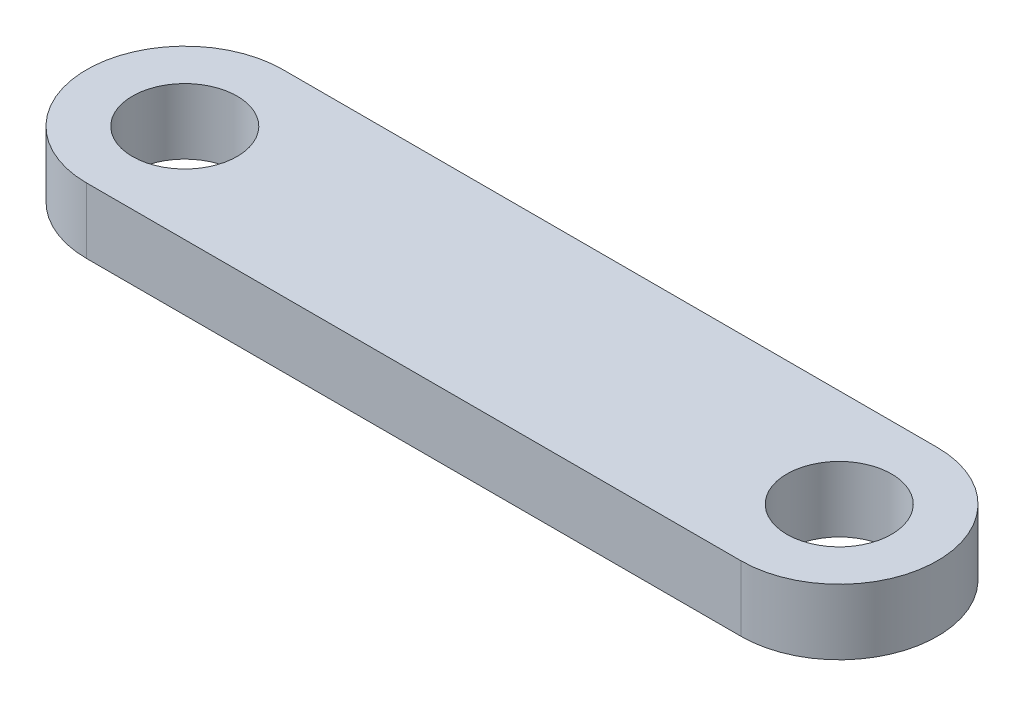
from build123d import *

# Parameters (mm, degrees)
SKETCH1_R           = 4
BOSS_EXTRUDE1_DEPTH = 5


with BuildPart() as part:
    # Sketch1 → Boss-Extrude1 (new body)
    with BuildSketch(Plane(origin=(0, 0, 0), x_dir=(1, 0, 0), z_dir=(0, 1, 0))):
        with BuildLine():
            Line((0, 7.5), (50, 7.5))
            ThreePointArc((50, 7.5), (57.5, 0), (50, -7.5))
            Line((50, -7.5), (0, -7.5))
            ThreePointArc((0, -7.5), (-7.5, 0), (0, 7.5))
        make_face()
        Circle(SKETCH1_R, mode=Mode.SUBTRACT)
        with Locations((50, 0)):
            Circle(SKETCH1_R, mode=Mode.SUBTRACT)
    extrude(amount=BOSS_EXTRUDE1_DEPTH)


solid = part.part
